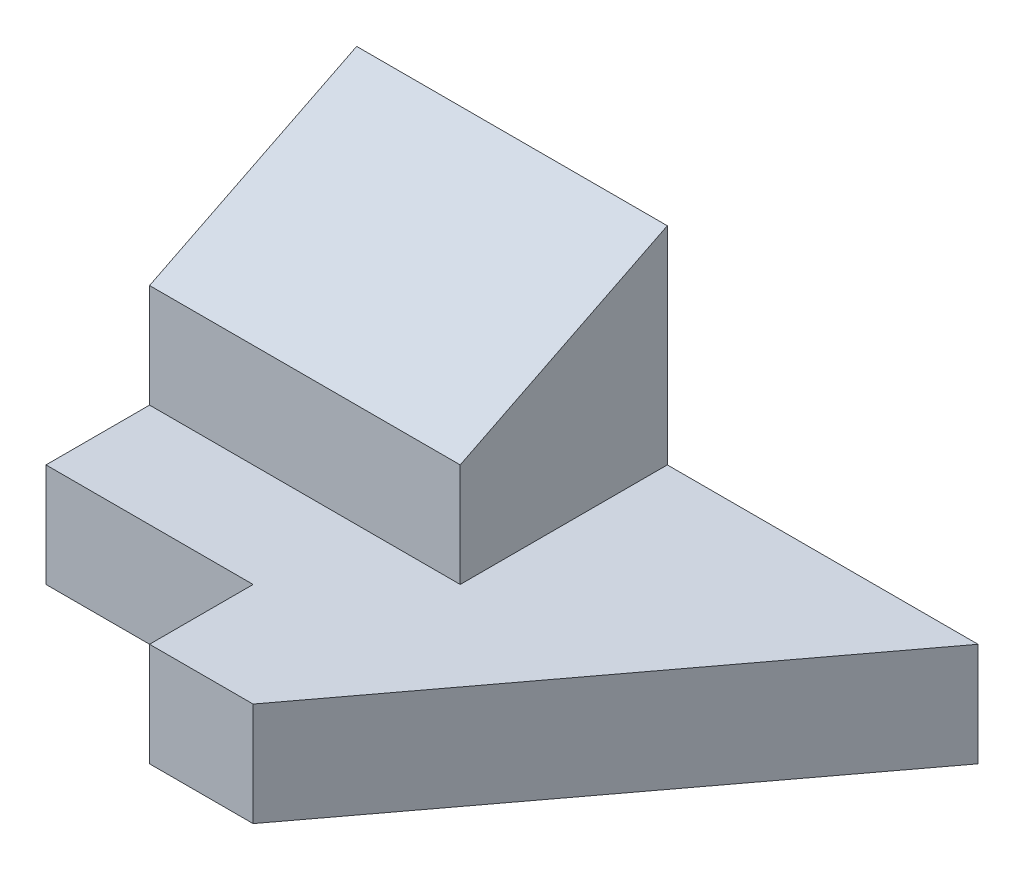
from build123d import *

# Parameters (mm, degrees)
EXTRUDE_1_DEPTH     = 5
SKETCH_1_3_W        = 15
SKETCH_1_3_H        = 10
EXTRUDE_2_DEPTH     = 15
CUT_EXTRUDE_1_DEPTH = 15
SCALE_1_SCALE       = 0.2


with BuildPart() as part:
    # 草圖1 → 填料-伸長1 (new body)
    with BuildSketch(Plane(origin=(0, 0, 0), x_dir=(1, 0, 0), z_dir=(0, 1, 0))):
        Polygon((-5, -10), (0, -10), (15, 10), (-15, 10), (-15, -5), (-5, -5), align=None)
    extrude(amount=EXTRUDE_1_DEPTH)

    # 草圖1<3> → 填料-伸長2 (add)
    with BuildSketch(Plane(origin=(0, 0, 0), x_dir=(1, 0, 0), z_dir=(0, 1, 0))):
        with Locations((-7.5, 5)):
            Rectangle(SKETCH_1_3_W, SKETCH_1_3_H)
    extrude(amount=EXTRUDE_2_DEPTH)

    # 草圖2 → 除料-伸長1 (cut)
    with BuildSketch(Plane(origin=(0, 0, 0), x_dir=(0, 0, -1), z_dir=(1, 0, 0))):
        Polygon((10, 15), (0, 10), (0, 15), align=None)
    extrude(amount=-CUT_EXTRUDE_1_DEPTH, mode=Mode.SUBTRACT)


with BuildPart() as part_1:
    # 縮放比例1: scaled about (-4.3, 4.8, -3.4)
    add(part.part.scale(SCALE_1_SCALE).moved(Location((-3.44, 3.84, -2.72))))


solid = part_1.part
